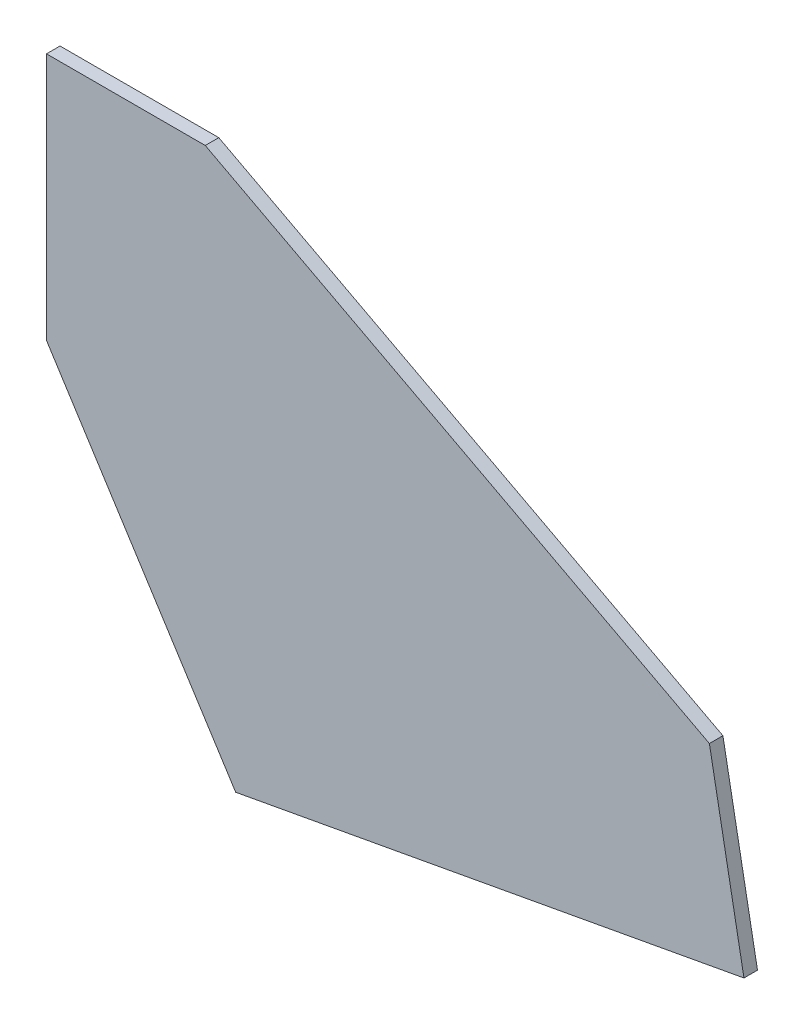
from build123d import *

# Parameters (mm, degrees)
BOSS_EXTRUDE1_DEPTH = 3.81


with BuildPart() as part:
    # Sketch2 → Boss-Extrude1 (new body)
    with BuildSketch(Plane.XY):
        Polygon((674.030273868, -1015.662728221), (817.091732774, -989.407840441), (807.360598061, -937.116427186), (665.469814468, -862.290887586), (620.785792456, -862.290887586), (620.785792456, -932.156619674), align=None)
    extrude(amount=BOSS_EXTRUDE1_DEPTH)


solid = part.part
